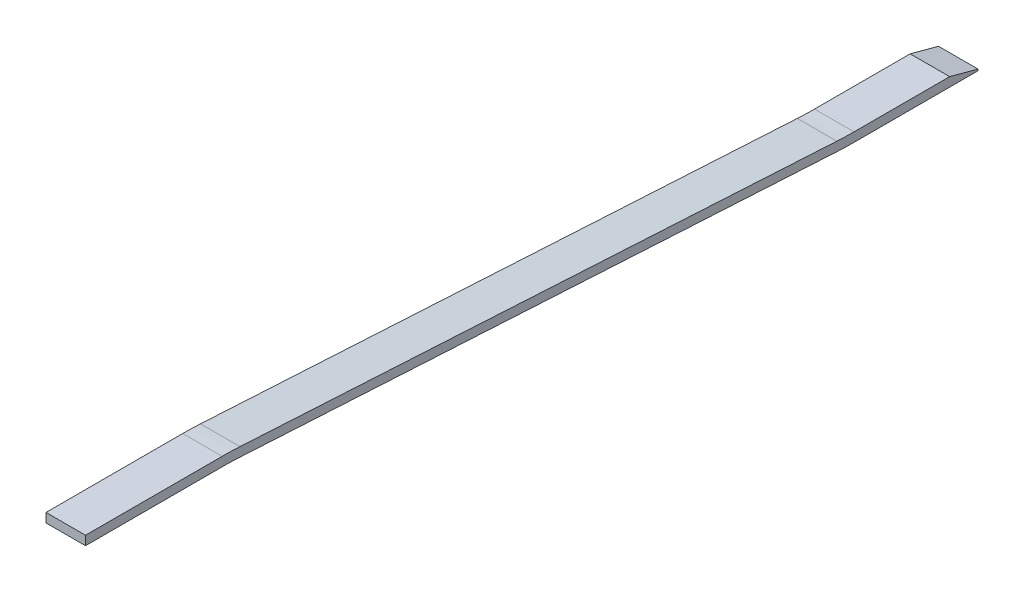
from build123d import *

# Parameters (mm, degrees)
EXTRUDE1_DEPTH = 6.5


with BuildPart() as part:
    # Sketch1 → Extrude1 (new body, symmetric)
    with BuildSketch(Plane(origin=(0, 0, 0), x_dir=(0, 0, -1), z_dir=(1, 0, 0))):
        with BuildLine():
            Line((55, 14), (100, 14))
            ThreePointArc((100, 14), (102.839816619, 13.959669075), (105.67734259, 13.838708831))
            Line((105.67734259, 13.838708831), (302.152337132, 2.666129904))
            ThreePointArc((302.152337132, 2.666129904), (305.074988882, 2.541540853), (308, 2.5))
            Line((308, 2.5), (348.803847577, 2.5))
            Line((348.803847577, 2.5), (348.803847577, 3))
            Line((348.803847577, 3), (339.473720558, 5.5))
            Line((339.473720558, 5.5), (308, 5.5))
            ThreePointArc((308, 5.5), (305.160183381, 5.540330925), (302.32265741, 5.661291169))
            Line((302.32265741, 5.661291169), (105.847662868, 16.833870096))
            ThreePointArc((105.847662868, 16.833870096), (102.925011118, 16.958459147), (100, 17))
            Line((100, 17), (55, 17))
            Line((55, 17), (55, 14))
        make_face()
    extrude(amount=EXTRUDE1_DEPTH, both=True)


solid = part.part
